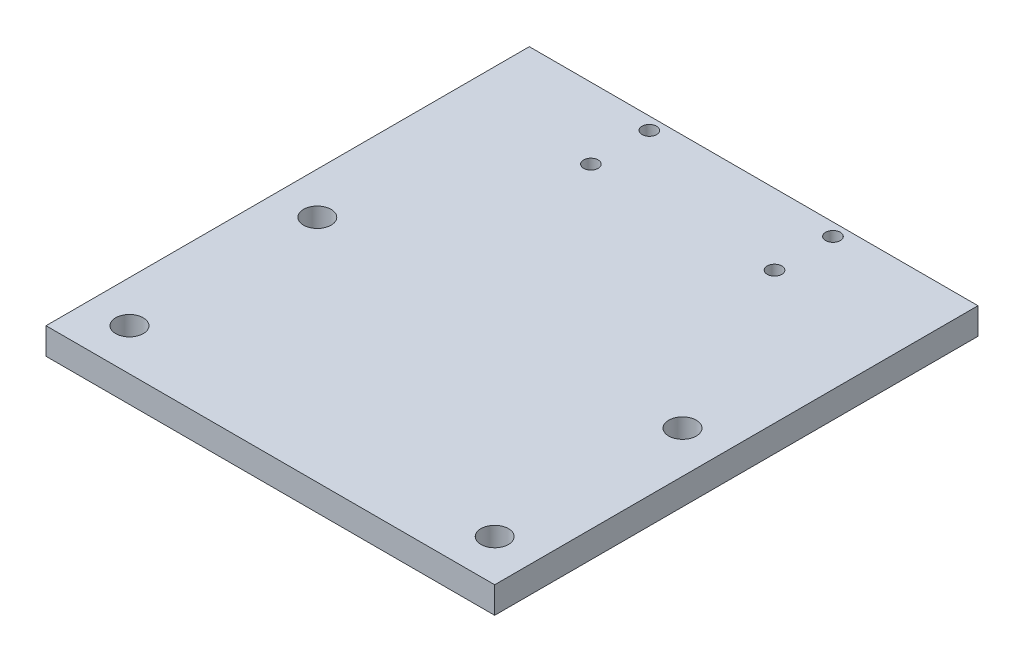
from build123d import *

# Parameters (mm, degrees)
SKETCH1_W           = 107.5
SKETCH1_H           = 115.8
SKETCH1_R           = 1.75
SKETCH1_R_2         = 3.3
BOSS_EXTRUDE1_DEPTH = 6.35


with BuildPart() as part:
    # Sketch1 → Boss-Extrude1 (new body)
    with BuildSketch(Plane(origin=(0, 0, 0), x_dir=(1, 0, 0), z_dir=(0, 1, 0))):
        with Locations((53.75, 57.9)):
            Rectangle(SKETCH1_W, SKETCH1_H)
        with Locations((31.75, 112.8)):
            Circle(SKETCH1_R, mode=Mode.SUBTRACT)
        with Locations((75.75, 98.8)):
            Circle(SKETCH1_R, mode=Mode.SUBTRACT)
        with Locations((31.75, 98.8)):
            Circle(SKETCH1_R, mode=Mode.SUBTRACT)
        with Locations((75.75, 112.8)):
            Circle(SKETCH1_R, mode=Mode.SUBTRACT)
        with Locations((10, 55)):
            Circle(SKETCH1_R_2, mode=Mode.SUBTRACT)
        with Locations((97.5, 55)):
            Circle(SKETCH1_R_2, mode=Mode.SUBTRACT)
        with Locations((10, 10)):
            Circle(SKETCH1_R_2, mode=Mode.SUBTRACT)
        with Locations((97.5, 10)):
            Circle(SKETCH1_R_2, mode=Mode.SUBTRACT)
    extrude(amount=BOSS_EXTRUDE1_DEPTH)


solid = part.part
